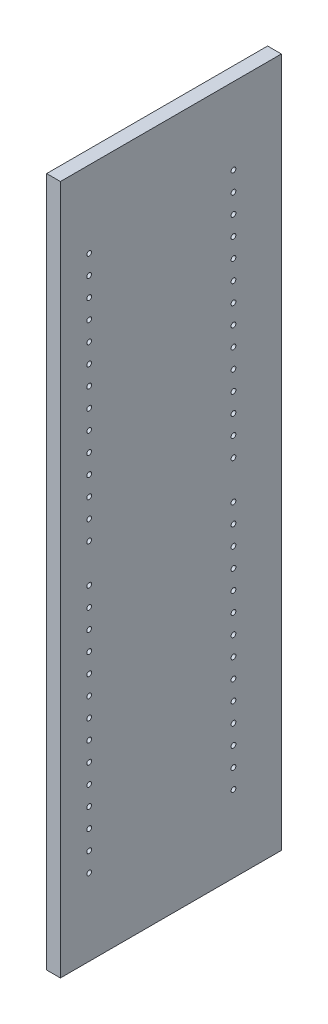
from build123d import *

# Parameters (mm, degrees)
SKETCH1_W           = 292.89375
SKETCH1_H           = 914.4
BOSS_EXTRUDE1_DEPTH = 18.25625
SKETCH3_R           = 3.175
CUT_EXTRUDE1_DEPTH  = 9.525


with BuildPart() as part:
    # Sketch1 → Boss-Extrude1 (new body)
    with BuildSketch(Plane(origin=(0, 0, 0), x_dir=(0, 0, -1), z_dir=(1, 0, 0))):
        Rectangle(SKETCH1_W, SKETCH1_H)
    extrude(amount=BOSS_EXTRUDE1_DEPTH)

    # Sketch3 → Cut-Extrude1 (cut)
    with BuildSketch(Plane(origin=(18.25625, 0, 0), x_dir=(0, 0, -1), z_dir=(1, 0, 0))):
        with Locations((-108.346875, 355.6)):
            Circle(SKETCH3_R)
        with Locations((-108.346875, 330.2)):
            Circle(SKETCH3_R)
        with Locations((-108.346875, 304.8)):
            Circle(SKETCH3_R)
        with Locations((-108.346875, 279.4)):
            Circle(SKETCH3_R)
        with Locations((-108.346875, 254)):
            Circle(SKETCH3_R)
        with Locations((-108.346875, 228.6)):
            Circle(SKETCH3_R)
        with Locations((-108.346875, 203.2)):
            Circle(SKETCH3_R)
        with Locations((-108.346875, 177.8)):
            Circle(SKETCH3_R)
        with Locations((-108.346875, 152.4)):
            Circle(SKETCH3_R)
        with Locations((-108.346875, 127)):
            Circle(SKETCH3_R)
        with Locations((-108.346875, 101.6)):
            Circle(SKETCH3_R)
        with Locations((-108.346875, 76.2)):
            Circle(SKETCH3_R)
        with Locations((-108.346875, 50.8)):
            Circle(SKETCH3_R)
        with Locations((-108.346875, 25.4)):
            Circle(SKETCH3_R)
        with Locations((82.946875, 25.4)):
            Circle(SKETCH3_R)
        with Locations((82.946875, 50.8)):
            Circle(SKETCH3_R)
        with Locations((82.946875, 76.2)):
            Circle(SKETCH3_R)
        with Locations((82.946875, 101.6)):
            Circle(SKETCH3_R)
        with Locations((82.946875, 127)):
            Circle(SKETCH3_R)
        with Locations((82.946875, 152.4)):
            Circle(SKETCH3_R)
        with Locations((82.946875, 177.8)):
            Circle(SKETCH3_R)
        with Locations((82.946875, 203.2)):
            Circle(SKETCH3_R)
        with Locations((82.946875, 228.6)):
            Circle(SKETCH3_R)
        with Locations((82.946875, 254)):
            Circle(SKETCH3_R)
        with Locations((82.946875, 279.4)):
            Circle(SKETCH3_R)
        with Locations((82.946875, 304.8)):
            Circle(SKETCH3_R)
        with Locations((82.946875, 330.2)):
            Circle(SKETCH3_R)
        with Locations((82.946875, 355.6)):
            Circle(SKETCH3_R)
        with Locations((82.946875, -355.6)):
            Circle(SKETCH3_R)
        with Locations((82.946875, -330.2)):
            Circle(SKETCH3_R)
        with Locations((82.946875, -304.8)):
            Circle(SKETCH3_R)
        with Locations((82.946875, -279.4)):
            Circle(SKETCH3_R)
        with Locations((82.946875, -254)):
            Circle(SKETCH3_R)
        with Locations((82.946875, -228.6)):
            Circle(SKETCH3_R)
        with Locations((82.946875, -203.2)):
            Circle(SKETCH3_R)
        with Locations((82.946875, -177.8)):
            Circle(SKETCH3_R)
        with Locations((82.946875, -152.4)):
            Circle(SKETCH3_R)
        with Locations((82.946875, -127)):
            Circle(SKETCH3_R)
        with Locations((82.946875, -101.6)):
            Circle(SKETCH3_R)
        with Locations((82.946875, -76.2)):
            Circle(SKETCH3_R)
        with Locations((82.946875, -50.8)):
            Circle(SKETCH3_R)
        with Locations((82.946875, -25.4)):
            Circle(SKETCH3_R)
        with Locations((-108.346875, -25.4)):
            Circle(SKETCH3_R)
        with Locations((-108.346875, -50.8)):
            Circle(SKETCH3_R)
        with Locations((-108.346875, -76.2)):
            Circle(SKETCH3_R)
        with Locations((-108.346875, -101.6)):
            Circle(SKETCH3_R)
        with Locations((-108.346875, -127)):
            Circle(SKETCH3_R)
        with Locations((-108.346875, -152.4)):
            Circle(SKETCH3_R)
        with Locations((-108.346875, -177.8)):
            Circle(SKETCH3_R)
        with Locations((-108.346875, -203.2)):
            Circle(SKETCH3_R)
        with Locations((-108.346875, -228.6)):
            Circle(SKETCH3_R)
        with Locations((-108.346875, -254)):
            Circle(SKETCH3_R)
        with Locations((-108.346875, -279.4)):
            Circle(SKETCH3_R)
        with Locations((-108.346875, -304.8)):
            Circle(SKETCH3_R)
        with Locations((-108.346875, -330.2)):
            Circle(SKETCH3_R)
        with Locations((-108.346875, -355.6)):
            Circle(SKETCH3_R)
    extrude(amount=-CUT_EXTRUDE1_DEPTH, mode=Mode.SUBTRACT)


solid = part.part
